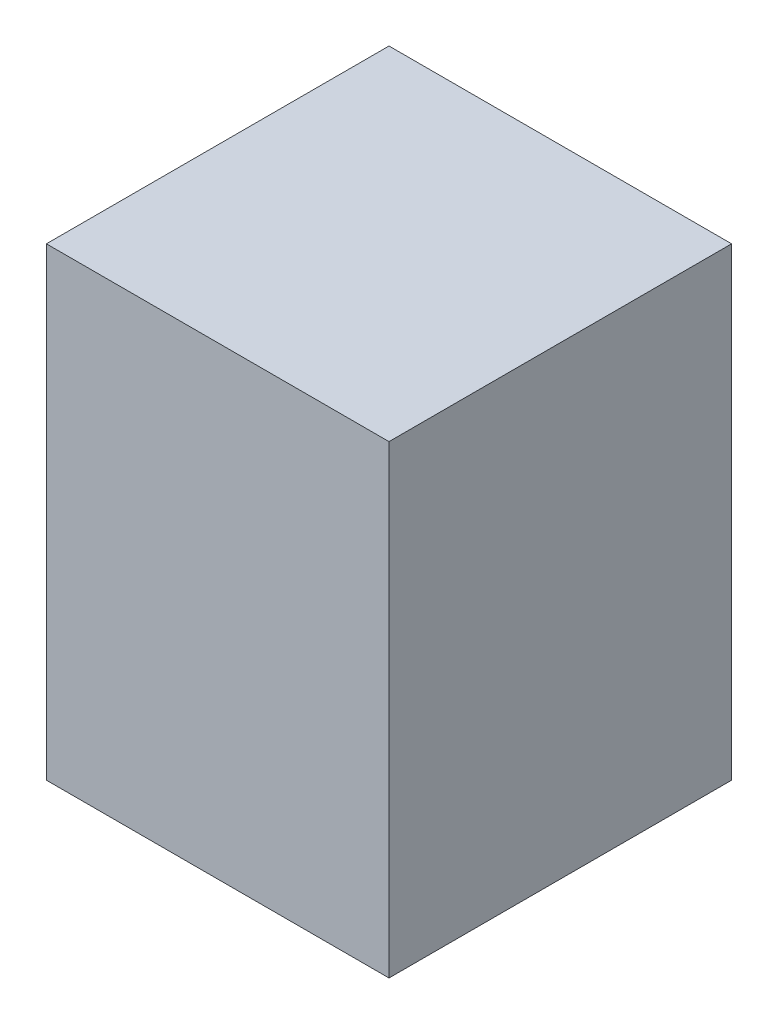
from build123d import *

# Parameters (mm, degrees)
SKETCH1_W           = 14.75
SKETCH1_H           = 14.75
BOSS_EXTRUDE1_DEPTH = 20


with BuildPart() as part:
    # Sketch1 → Boss-Extrude1 (new body)
    with BuildSketch(Plane(origin=(0, 0, 0), x_dir=(1, 0, 0), z_dir=(0, 1, 0))):
        Rectangle(SKETCH1_W, SKETCH1_H)
    extrude(amount=BOSS_EXTRUDE1_DEPTH)


solid = part.part
